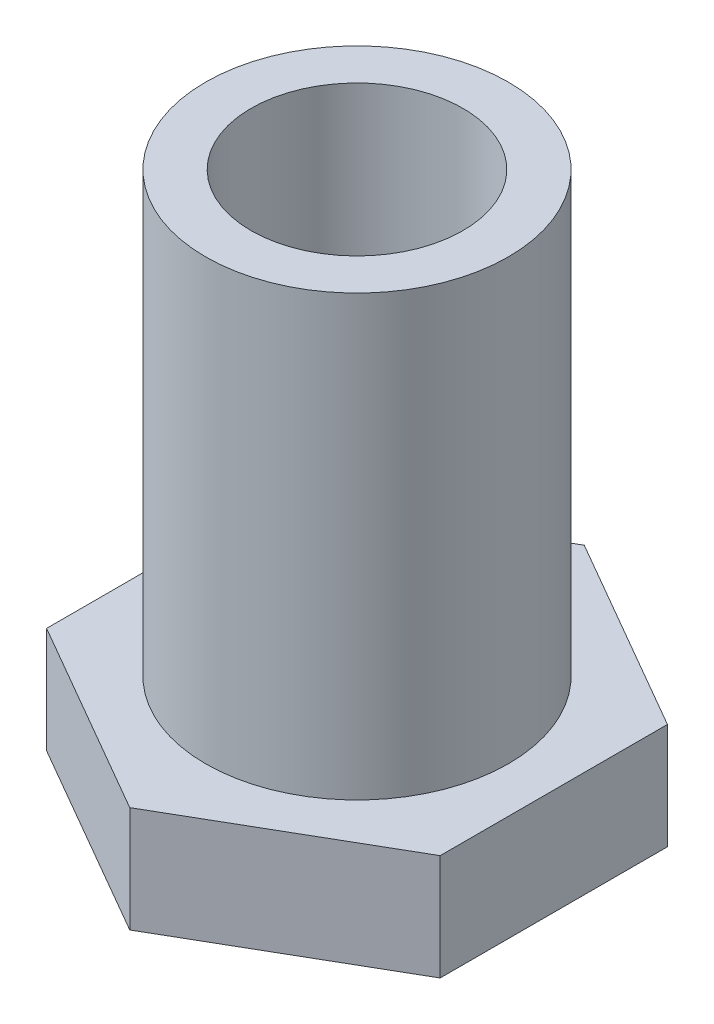
from build123d import *

# Parameters (mm, degrees)
CROQUIS1_R              = 5
CROQUIS1_R_2            = 3.5
SALIENTE_EXTRUIR1_DEPTH = 18
CROQUIS1_3_R            = 5
SALIENTE_EXTRUIR2_DEPTH = 3.5


with BuildPart() as part:
    # Croquis1 → Saliente-Extruir1 (new body)
    with BuildSketch(Plane(origin=(0, 0, 0), x_dir=(1, 0, 0), z_dir=(0, 1, 0))):
        Circle(CROQUIS1_R)
        Circle(CROQUIS1_R_2, mode=Mode.SUBTRACT)
    extrude(amount=SALIENTE_EXTRUIR1_DEPTH)

    # Croquis1_3 → Saliente-Extruir2 (add)
    with BuildSketch(Plane(origin=(0, 0, 0), x_dir=(1, 0, 0), z_dir=(0, 1, 0))):
        Polygon((6.5, -3.75277675), (6.5, 3.75277675), (0, 7.505553499), (-6.5, 3.75277675), (-6.5, -3.75277675), (0, -7.505553499), align=None)
        Circle(CROQUIS1_3_R, mode=Mode.SUBTRACT)
    extrude(amount=SALIENTE_EXTRUIR2_DEPTH)


solid = part.part
